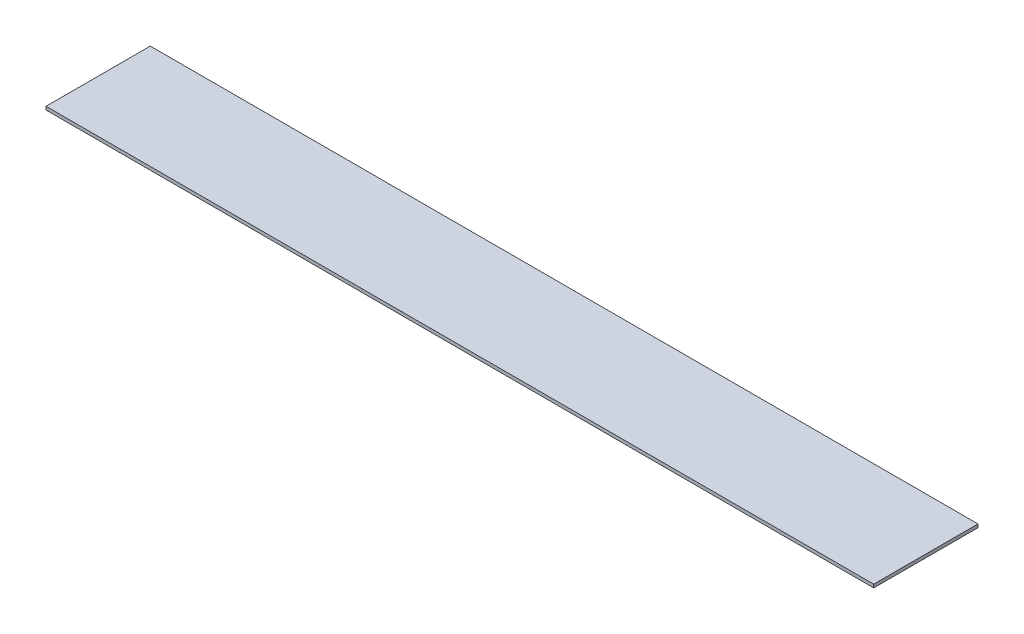
from build123d import *

# Parameters (mm, degrees)
SKETCH1_W           = 127
SKETCH1_H           = 16
BOSS_EXTRUDE1_DEPTH = 0.5


with BuildPart() as part:
    # Sketch1 → Boss-Extrude1 (new body)
    with BuildSketch(Plane(origin=(0, 0, 0), x_dir=(1, 0, 0), z_dir=(0, 1, 0))):
        Rectangle(SKETCH1_W, SKETCH1_H)
    extrude(amount=BOSS_EXTRUDE1_DEPTH)


solid = part.part
